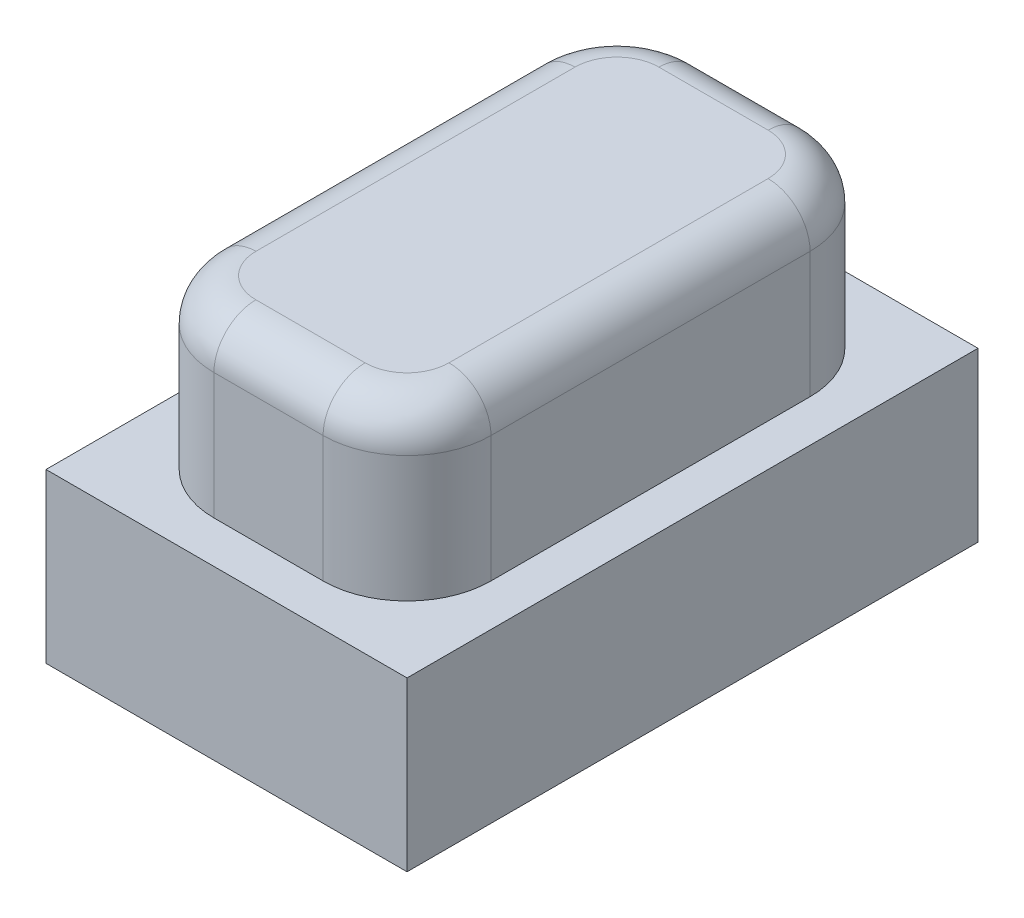
from build123d import *

# Parameters (mm, degrees)
EXTRUDE_1_DEPTH = 2
SKETCH_2_W      = 4.3
SKETCH_2_H      = 6.8
EXTRUDE_2_DEPTH = 1
SKETCH_4_W      = 4.3
SKETCH_4_H      = 6.8
SKETCH_4_W_2    = 3.3
SKETCH_4_H_2    = 5.8
EXTRUDE_3_DEPTH = 1
FILLET_1_R      = 0.5


with BuildPart() as part:
    # 草图1 → 凸台-拉伸1 (new body)
    with BuildSketch(Plane(origin=(0, 0, 0), x_dir=(1, 0, 0), z_dir=(0, 1, 0))):
        with BuildLine():
            Line((-0.65, -2.9), (0.65, -2.9))
            ThreePointArc((0.65, -2.9), (1.357106781, -2.607106781), (1.65, -1.9))
            Line((1.65, -1.9), (1.65, 1.9))
            ThreePointArc((1.65, 1.9), (1.357106781, 2.607106781), (0.65, 2.9))
            Line((0.65, 2.9), (-0.65, 2.9))
            ThreePointArc((-0.65, 2.9), (-1.357106781, 2.607106781), (-1.65, 1.9))
            Line((-1.65, 1.9), (-1.65, -1.9))
            ThreePointArc((-1.65, -1.9), (-1.357106781, -2.607106781), (-0.65, -2.9))
        make_face()
    extrude(amount=EXTRUDE_1_DEPTH)

    # 草图2 → 凸台-拉伸2 (add)
    with BuildSketch(Plane.XZ):
        Rectangle(SKETCH_2_W, SKETCH_2_H)
    extrude(amount=EXTRUDE_2_DEPTH)

    # 草图4 → 凸台-拉伸3 (add)
    with BuildSketch(Plane.XZ.offset(1)):
        Rectangle(SKETCH_4_W, SKETCH_4_H)
        Rectangle(SKETCH_4_W_2, SKETCH_4_H_2, mode=Mode.SUBTRACT)
    extrude(amount=EXTRUDE_3_DEPTH)

    # 圆角1
    fillet_1_edges = [part.edges().sort_by_distance(p)[0] for p in [
        (1.357106781, 2, -2.607106781),
        (0, 2, -2.9),
        (-1.357106781, 2, -2.607106781),
        (-1.65, 2, 0),
        (-1.357106781, 2, 2.607106781),
        (0, 2, 2.9),
        (1.357106781, 2, 2.607106781),
        (1.65, 2, 0),
    ]]
    fillet(fillet_1_edges, radius=FILLET_1_R)


solid = part.part
